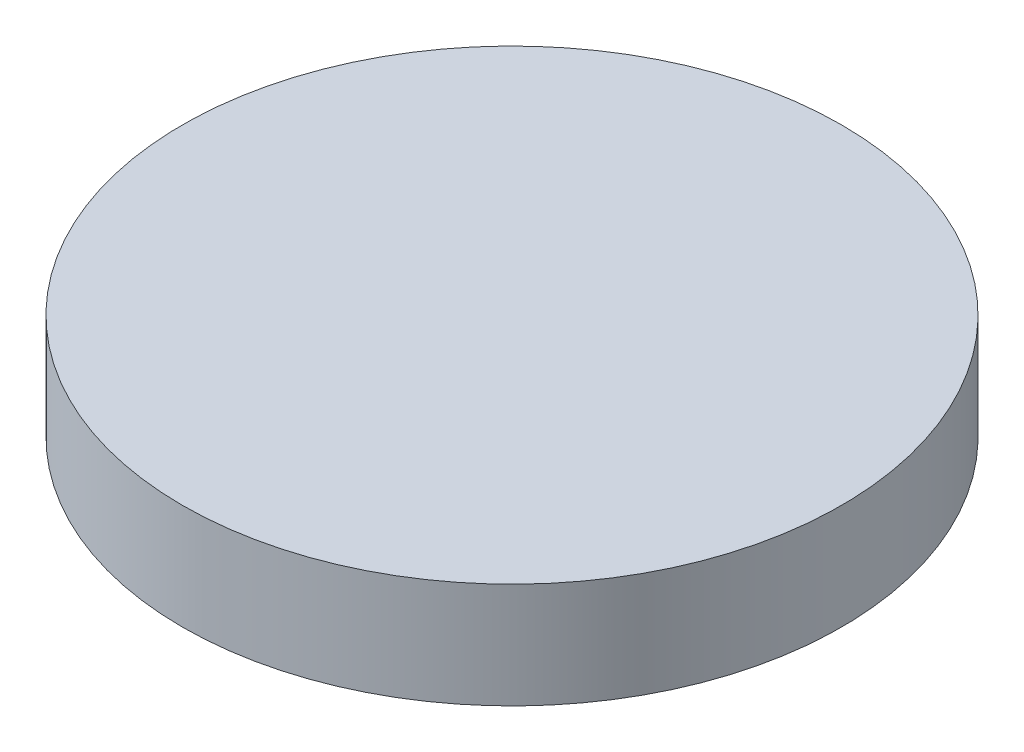
from build123d import *

# Parameters (mm, degrees)
SKETCH_1_R      = 6.25
EXTRUDE_1_DEPTH = 2


with BuildPart() as part:
    # 草图1 → 凸台-拉伸1 (new body)
    with BuildSketch(Plane(origin=(0, 0, 0), x_dir=(1, 0, 0), z_dir=(0, 1, 0))):
        with Locations(Location((0, 0, 0), (0, 0, 270))):  # turned: the seam where the file's is
            Circle(SKETCH_1_R)
    extrude(amount=EXTRUDE_1_DEPTH)


solid = part.part
